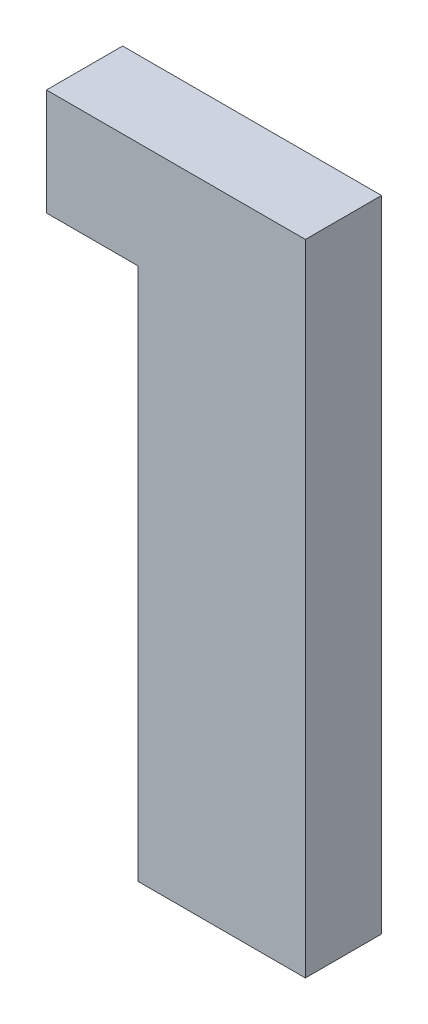
from build123d import *

# Parameters (mm, degrees)
SKETCH2_W           = 7.62
SKETCH2_H           = 8.89
SKETCH2_W_2         = 13.97
SKETCH2_H_2         = 44.45
BOSS_EXTRUDE1_DEPTH = 6.35
SKETCH3_R           = 4.0005
CUT_EXTRUDE1_DEPTH  = 2.794
CUT_EXTRUDE2_DEPTH  = 1.5875


with BuildPart() as part:
    # Sketch2 → Boss-Extrude1 (new body)
    with BuildSketch(Plane.XY):
        with Locations((-17.78, 48.895)):
            Rectangle(SKETCH2_W, SKETCH2_H)
        with Locations((-6.985, 48.895)):
            Rectangle(SKETCH2_W_2, SKETCH2_H)
        with Locations((-6.985, 22.225)):
            Rectangle(SKETCH2_W_2, SKETCH2_H_2)
    extrude(amount=BOSS_EXTRUDE1_DEPTH)

    # Sketch3 → Cut-Extrude1 (cut)
    with BuildSketch(Plane(origin=(0, 0, 0), x_dir=(-1, 0, 0), z_dir=(0, 0, -1))):
        with Locations((6.985, 15.24)):
            Circle(SKETCH3_R)
    extrude(amount=-CUT_EXTRUDE1_DEPTH, mode=Mode.SUBTRACT)

    # Sketch4 → Cut-Extrude2 (cut)
    with BuildSketch(Plane(origin=(0, 0, 0), x_dir=(-1, 0, 0), z_dir=(0, 0, -1))):
        Polygon((6.985, 29.718), (9.017, 29.718), (9.017, 15.24), (9.017, 0.762), (4.953, 0.762), (4.953, 15.24), (4.953, 29.718), align=None)
    extrude(amount=-CUT_EXTRUDE2_DEPTH, mode=Mode.SUBTRACT)


solid = part.part
